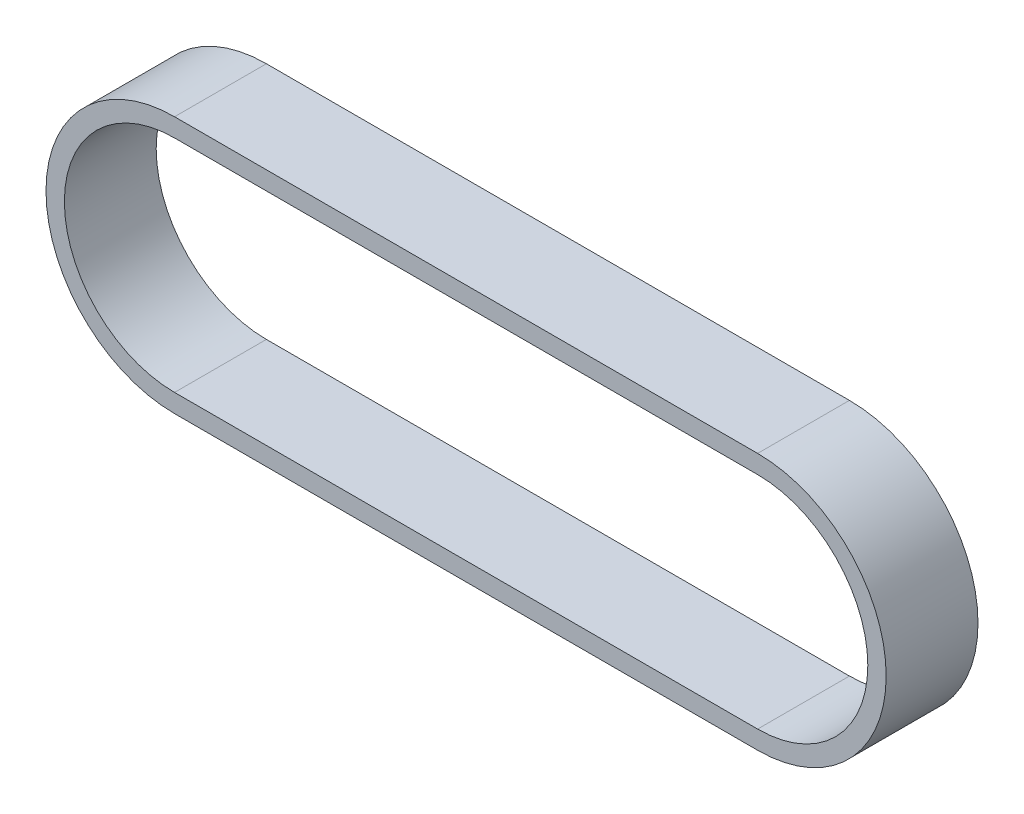
from build123d import *

# Parameters (mm, degrees)
EXTRUDE_1_DEPTH = 10


with BuildPart() as part:
    # 草图1 → 凸台-拉伸1 (new body)
    with BuildSketch(Plane.XY):
        with BuildLine():
            Line((0, 14), (63.5, 14))
            ThreePointArc((63.5, 14), (77.5, 0), (63.5, -14))
            Line((63.5, -14), (0, -14))
            ThreePointArc((0, -14), (-14, 0), (0, 14))
        make_face()
        with BuildLine():
            Line((0, 12), (63.5, 12))
            ThreePointArc((63.5, 12), (75.5, 0), (63.5, -12))
            Line((63.5, -12), (0, -12))
            ThreePointArc((0, -12), (-12, 0), (0, 12))
        make_face(mode=Mode.SUBTRACT)
    extrude(amount=EXTRUDE_1_DEPTH)


solid = part.part
